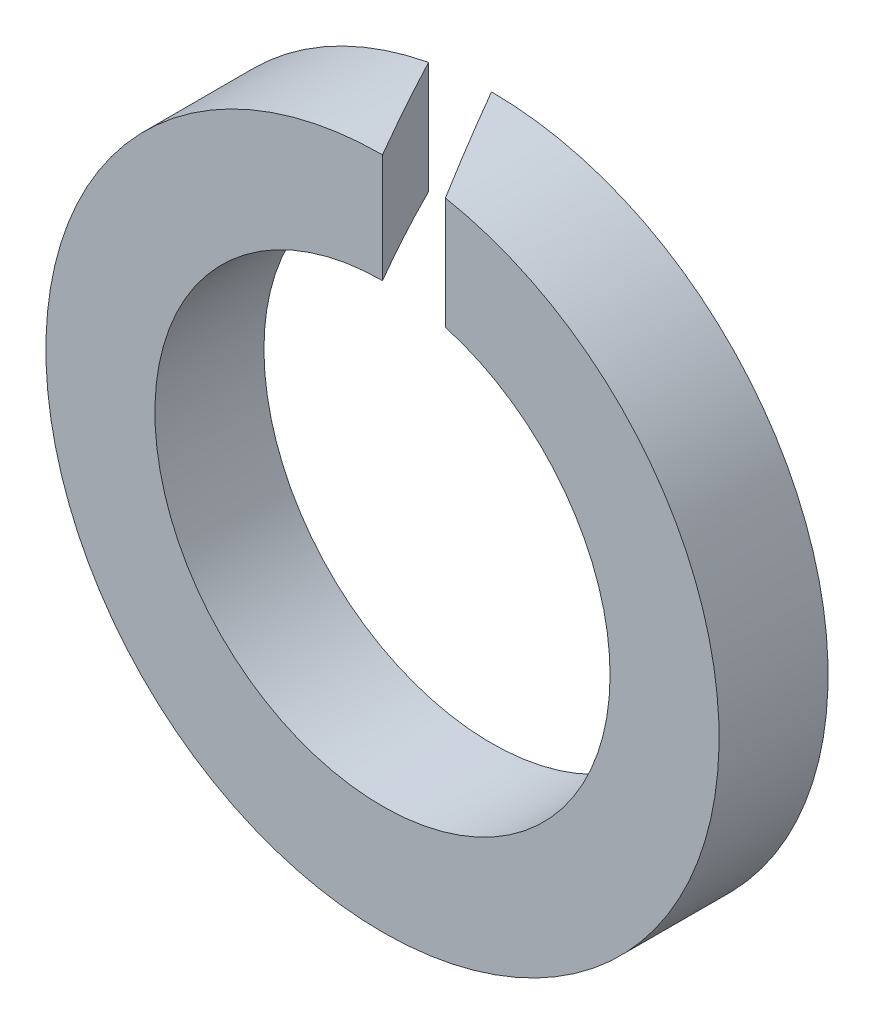
from build123d import *

# Parameters (mm, degrees)
SKETCH1_R          = 4.94
SKETCH1_R_2        = 3.34
BASE_EXTRUDE_DEPTH = 1.6
CUT_EXTRUDE1_DEPTH = 5.94


with BuildPart() as part:
    # Sketch1 → Base-Extrude (new body)
    with BuildSketch(Plane.XY):
        Circle(SKETCH1_R)
        Circle(SKETCH1_R_2, mode=Mode.SUBTRACT)
    extrude(amount=-BASE_EXTRUDE_DEPTH)

    # Sketch2 → Cut-Extrude1 (cut, through all)
    with BuildSketch(Plane(origin=(0, 0, 0), x_dir=(1, 0, 0), z_dir=(0, 1, 0))):
        Polygon((0, 1.6), (0.923760431, 0), (0, 0), (-0.923760431, 1.6), align=None)
    extrude(amount=CUT_EXTRUDE1_DEPTH, mode=Mode.SUBTRACT)


solid = part.part
